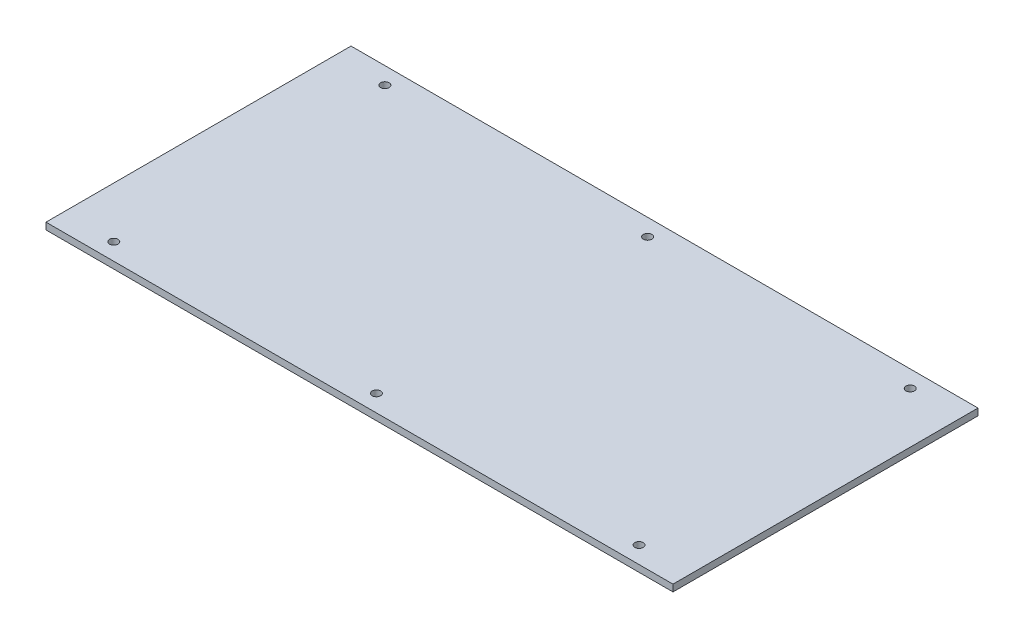
from build123d import *

# Parameters (mm, degrees)
SKETCH1_W           = 370
SKETCH1_H           = 180
SKETCH1_R           = 2.5
BOSS_EXTRUDE1_DEPTH = 4


with BuildPart() as part:
    # Sketch1 → Boss-Extrude1 (new body)
    with BuildSketch(Plane(origin=(0, 0, 0), x_dir=(1, 0, 0), z_dir=(0, 1, 0))):
        Rectangle(SKETCH1_W, SKETCH1_H)
        with Locations((-155, 80)):
            Circle(SKETCH1_R, mode=Mode.SUBTRACT)
        with Locations((0, 80)):
            Circle(SKETCH1_R, mode=Mode.SUBTRACT)
        with Locations((155, 80)):
            Circle(SKETCH1_R, mode=Mode.SUBTRACT)
        with Locations((-155, -80)):
            Circle(SKETCH1_R, mode=Mode.SUBTRACT)
        with Locations((0, -80)):
            Circle(SKETCH1_R, mode=Mode.SUBTRACT)
        with Locations((155, -80)):
            Circle(SKETCH1_R, mode=Mode.SUBTRACT)
    extrude(amount=BOSS_EXTRUDE1_DEPTH)


solid = part.part
